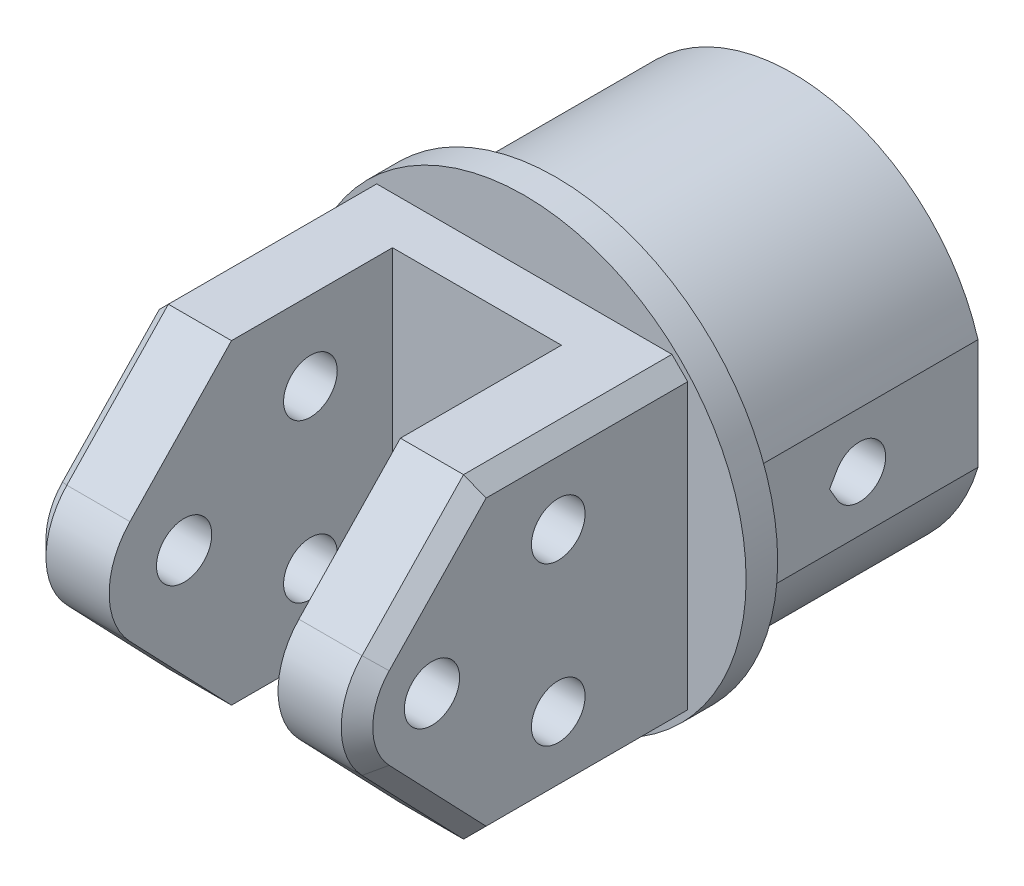
from build123d import *

# Parameters (mm, degrees)
SKETCH_1_R               = 6.325
EXTRUDE_1_DEPTH          = 15
SKETCH_2_W               = 20.7
SKETCH_2_H               = 20
EXTRUDE_2_DEPTH          = 5
SKETCH_3_W               = 5
SKETCH_3_H               = 20
EXTRUDE_3_DEPTH          = 10.2
SKETCH_4_R               = 1.7
CUT_EXTRUDE_1_DEPTH      = 21.932331452
CUT_EXTRUDE_1_DEPTH_BACK = 21.932331452
SKETCH_5_R               = 1.65
CUT_EXTRUDE_2_DEPTH      = 21.932331452
CUT_EXTRUDE_2_DEPTH_BACK = 21.932331452
SKETCH_6_R               = 1.75
EXTRUDE_4_DEPTH          = 5
CHAMFER_2_SIZE           = 1
CHAMFER_3_SIZE           = 1
CUT_EXTRUDE_3_DEPTH      = 33.153149146
CUT_EXTRUDE_3_DEPTH_BACK = 33.153149146
SKETCH_9_R               = 12.25
SKETCH_9_R_2             = 9.25
EXTRUDE_5_DEPTH          = 15
SKETCH_10_R              = 14.05
EXTRUDE_6_DEPTH          = 2
CUT_EXTRUDE_4_DEPTH      = 31.356342006
CUT_EXTRUDE_4_DEPTH_BACK = 31.356342006
CUT_EXTRUDE_5_REACH      = 44.837
SKETCH_12_W              = 4.440498429
SKETCH_12_H              = 7
SKETCH_12_W_2            = 5.469845286


with BuildPart() as part:
    # ｽｹｯﾁ1 → ﾎﾞｽ - 押し出し1 (new body)
    with BuildSketch(Plane.XY):
        Circle(SKETCH_1_R)
    extrude(amount=-EXTRUDE_1_DEPTH)

    # ｽｹｯﾁ2 → ﾎﾞｽ - 押し出し2 (add)
    with BuildSketch(Plane.XY):
        Rectangle(SKETCH_2_W, SKETCH_2_H)
    extrude(amount=EXTRUDE_2_DEPTH)

    # ｽｹｯﾁ3 → ﾎﾞｽ - 押し出し3 (add)
    with BuildSketch(Plane.XY.offset(5)):
        with Locations((7.85, 0)):
            Rectangle(SKETCH_3_W, SKETCH_3_H)
        with Locations((-7.85, 0)):
            Rectangle(SKETCH_3_W, SKETCH_3_H)
    extrude(amount=EXTRUDE_3_DEPTH)

    # ｽｹｯﾁ4 → ｶｯﾄ - 押し出し1 (cut, two sides)
    with BuildSketch(Plane(origin=(0, 0, 0), x_dir=(0, 0, -1), z_dir=(1, 0, 0))) as cut_extrude_1_sk:
        with Locations((-10.2, 5)):
            Circle(SKETCH_4_R)
        with Locations(Location((-10.2, -5, 0), (0, 0, 270))):
            Circle(SKETCH_4_R)
    extrude(amount=CUT_EXTRUDE_1_DEPTH, mode=Mode.SUBTRACT)
    extrude(cut_extrude_1_sk.sketch, amount=-CUT_EXTRUDE_1_DEPTH_BACK, mode=Mode.SUBTRACT)

    # ｽｹｯﾁ5 → ｶｯﾄ - 押し出し2 (cut, two sides)
    with BuildSketch(Plane(origin=(0, 0, 0), x_dir=(0, 0, -1), z_dir=(1, 0, 0))) as cut_extrude_2_sk:
        with Locations((7.5, 0)):
            Circle(SKETCH_5_R)
    extrude(amount=CUT_EXTRUDE_2_DEPTH, mode=Mode.SUBTRACT)
    extrude(cut_extrude_2_sk.sketch, amount=-CUT_EXTRUDE_2_DEPTH_BACK, mode=Mode.SUBTRACT)

    # ｽｹｯﾁ6 → ﾎﾞｽ - 押し出し4 (add)
    with BuildSketch(Plane.ZY.offset(10.35)):
        with BuildLine():
            Line((15.2, 10), (21.630535845, 3.285410753))
            ThreePointArc((21.630535845, 3.285410753), (22.95, 0), (21.630535845, -3.285410753))
            Line((21.630535845, -3.285410753), (15.2, -10))
            Line((15.2, -10), (15.2, 10))
        make_face()
        with Locations(Location((18.2, 0, 0), (0, 0, 270))):
            Circle(SKETCH_6_R, mode=Mode.SUBTRACT)
    extrude_4 = extrude(amount=-EXTRUDE_4_DEPTH)

    # ﾐﾗｰ1: ﾎﾞｽ - 押し出し4 across plane
    add(extrude_4.mirror(Plane(origin=(0, 0, 0), x_dir=(0, 0, 1), z_dir=(1, 0, 0))))

    # 面取り2
    chamfer_2_edges = [part.edges().sort_by_distance(p)[0] for p in [
        (10.35, -10, 7.6),
        (10.35, 10, 7.6),
        (-10.35, -6.642705377, 18.415267922),
        (-10.35, 0, 22.95),
        (-10.35, 6.642705377, 18.415267922),
        (-10.35, 10, 7.6),
        (-10.35, -10, 7.6),
        (10.35, -6.642705377, 18.415267922),
        (10.35, 0, 22.95),
        (10.35, 6.642705377, 18.415267922),
    ]]
    chamfer(chamfer_2_edges, length=CHAMFER_2_SIZE)

    # 面取り3
    chamfer_3_edges = [part.edges().sort_by_distance(p)[0] for p in [
        (-6.325, 0, -15),
    ]]
    chamfer(chamfer_3_edges, length=CHAMFER_3_SIZE)

    # ｽｹｯﾁ8 → ｶｯﾄ - 押し出し3 (cut, two sides)
    with BuildSketch(Plane(origin=(0, 10, 0), x_dir=(1, 0, 0), z_dir=(0, 1, 0))) as cut_extrude_3_sk:
        Polygon((-104.749244062, 0), (-16.325065883, 0), (21.444424523, 0), (109.868602701, 0), (109.868602701, 176.848356357), (-104.749244062, 176.848356357), align=None)
    extrude(amount=CUT_EXTRUDE_3_DEPTH, mode=Mode.SUBTRACT)
    extrude(cut_extrude_3_sk.sketch, amount=-CUT_EXTRUDE_3_DEPTH_BACK, mode=Mode.SUBTRACT)

    # ｽｹｯﾁ9 → ﾎﾞｽ - 押し出し5 (add)
    with BuildSketch(Plane(origin=(0, 0, 0), x_dir=(-1, 0, 0), z_dir=(0, 0, -1))):
        with Locations(Location((0, 0, 0), (0, 0, 212.338995303))):
            Circle(SKETCH_9_R)
        Circle(SKETCH_9_R_2, mode=Mode.SUBTRACT)
    extrude(amount=EXTRUDE_5_DEPTH)

    # ｽｹｯﾁ10 → ﾎﾞｽ - 押し出し6 (add)
    with BuildSketch(Plane.XY):
        Circle(SKETCH_10_R)
    extrude(amount=EXTRUDE_6_DEPTH)

    # ｽｹｯﾁ11 → ｶｯﾄ - 押し出し4 (cut, two sides)
    with BuildSketch(Plane(origin=(0, 0, 0), x_dir=(0, 0, -1), z_dir=(1, 0, 0))) as cut_extrude_4_sk:
        with BuildLine():
            Line((6.071058084, 0.825), (5.594744112, 0))
            Line((5.594744112, 0), (6.071058084, -0.825))
            ThreePointArc((6.071058084, -0.825), (9.15, 0), (6.071058084, 0.825))
        make_face()
    extrude(amount=CUT_EXTRUDE_4_DEPTH, mode=Mode.SUBTRACT)
    extrude(cut_extrude_4_sk.sketch, amount=-CUT_EXTRUDE_4_DEPTH_BACK, mode=Mode.SUBTRACT)

    # ｶｯﾄ - 押し出し5: up to this face of the body (flat: up to its plane)
    cut_extrude_5_end = Plane(part.part.faces().sort_by_distance((-10.685757389, 6.765438958, 0))[0])
    # ｽｹｯﾁ12 → ｶｯﾄ - 押し出し5 (cut, up to the picked face)
    with BuildSketch(Plane(origin=(0, 0, -15), x_dir=(-1, 0, 0), z_dir=(0, 0, -1)), mode=Mode.PRIVATE) as cut_extrude_5_sk1:
        with Locations((-13.959606096, 0)):
            Rectangle(SKETCH_12_W, SKETCH_12_H)
    cut_extrude_5_tool1 = split(extrude(cut_extrude_5_sk1.sketch, amount=-CUT_EXTRUDE_5_REACH, mode=Mode.PRIVATE), bisect_by=cut_extrude_5_end, keep=Keep.BOTH, mode=Mode.PRIVATE)
    # ｽｹｯﾁ12 → ｶｯﾄ - 押し出し5 (cut, up to the picked face)
    with BuildSketch(Plane(origin=(0, 0, -15), x_dir=(-1, 0, 0), z_dir=(0, 0, -1)), mode=Mode.PRIVATE) as cut_extrude_5_sk2:
        with Locations((14.474279525, 0)):
            Rectangle(SKETCH_12_W_2, SKETCH_12_H)
    cut_extrude_5_tool2 = split(extrude(cut_extrude_5_sk2.sketch, amount=-CUT_EXTRUDE_5_REACH, mode=Mode.PRIVATE), bisect_by=cut_extrude_5_end, keep=Keep.BOTH, mode=Mode.PRIVATE)
    add(cut_extrude_5_tool1.solids().sort_by(Axis((13.959606, 0, -15), (0, 0, 1)))[0], mode=Mode.SUBTRACT)
    add(cut_extrude_5_tool2.solids().sort_by(Axis((-14.47428, 0, -15), (0, 0, 1)))[0], mode=Mode.SUBTRACT)


solid = part.part
